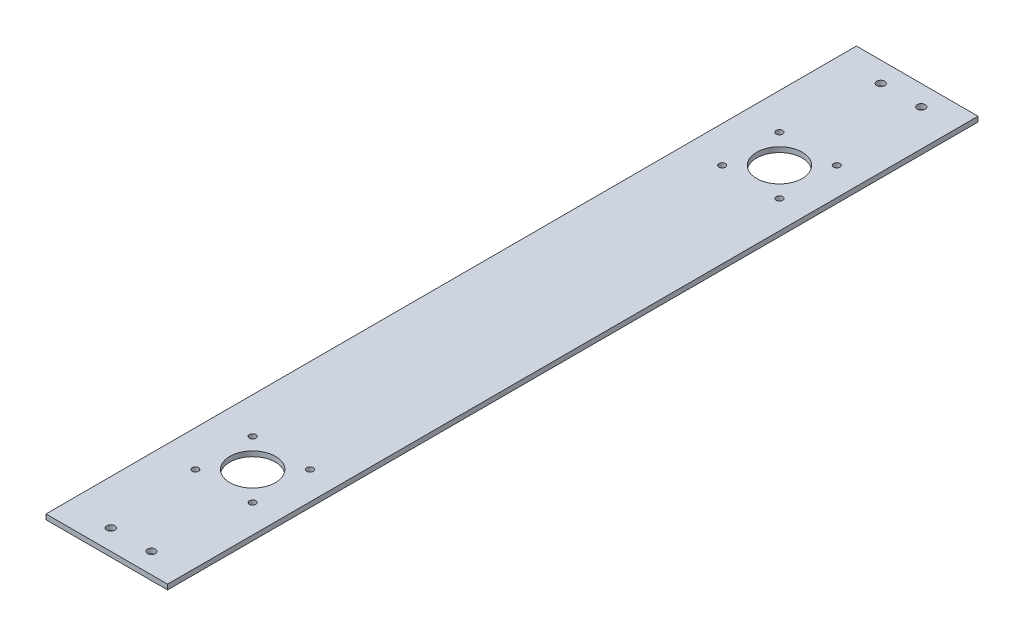
from build123d import *

# Parameters (mm, degrees)
SKETCH1_W               = 406.4
SKETCH1_H               = 508
BOSS_EXTRUDE1_DEPTH     = 3.175
SKETCH2_R               = 14.2875
CUT_EXTRUDE1_DEPTH      = 3.175
SKETCH3_R               = 2.4892
CUT_EXTRUDE2_DEPTH      = 1
CUT_EXTRUDE2_DEPTH_BACK = 4.175
SKETCH4_R               = 2.0193
CUT_EXTRUDE3_DEPTH      = 1
CUT_EXTRUDE3_DEPTH_BACK = 4.175
CUT_EXTRUDE4_REACH      = 5.175
SKETCH5_W               = 124.46
SKETCH5_H               = 508
SKETCH5_W_2             = 205.74


with BuildPart() as part:
    # Sketch1 → Boss-Extrude1 (new body)
    with BuildSketch(Plane(origin=(0, 0, 0), x_dir=(1, 0, 0), z_dir=(0, 1, 0))):
        with Locations((203.2, 254)):
            Rectangle(SKETCH1_W, SKETCH1_H)
    extrude(amount=BOSS_EXTRUDE1_DEPTH)

    # Sketch2 → Cut-Extrude1 (cut)
    with BuildSketch(Plane(origin=(0, 3.175, 0), x_dir=(1, 0, 0), z_dir=(0, 1, 0))):
        with Locations((50.8, 419.1)):
            Circle(SKETCH2_R)
        with Locations((165.1, 419.1)):
            Circle(SKETCH2_R)
        with Locations((50.8, 88.9)):
            Circle(SKETCH2_R)
        with Locations((165.1, 88.9)):
            Circle(SKETCH2_R)
    extrude(amount=-CUT_EXTRUDE1_DEPTH, mode=Mode.SUBTRACT)

    # Sketch3 → Cut-Extrude2 (cut, two sides)
    with BuildSketch(Plane(origin=(0, 3.175, 0), x_dir=(1, 0, 0), z_dir=(0, 1, 0))) as cut_extrude2_sk:
        with Locations((38.1, 12.7)):
            Circle(SKETCH3_R)
        with Locations((63.5, 12.7)):
            Circle(SKETCH3_R)
        with Locations((152.4, 12.7)):
            Circle(SKETCH3_R)
        with Locations((177.8, 12.7)):
            Circle(SKETCH3_R)
        with Locations((203.2, 12.7)):
            Circle(SKETCH3_R)
        with Locations((228.6, 12.7)):
            Circle(SKETCH3_R)
        with Locations((254, 12.7)):
            Circle(SKETCH3_R)
        with Locations((279.4, 12.7)):
            Circle(SKETCH3_R)
        with Locations((304.8, 12.7)):
            Circle(SKETCH3_R)
        with Locations((330.2, 12.7)):
            Circle(SKETCH3_R)
        with Locations((355.6, 12.7)):
            Circle(SKETCH3_R)
        with Locations((381, 12.7)):
            Circle(SKETCH3_R)
        with Locations((381, 495.3)):
            Circle(SKETCH3_R)
        with Locations((355.6, 495.3)):
            Circle(SKETCH3_R)
        with Locations((330.2, 495.3)):
            Circle(SKETCH3_R)
        with Locations((304.8, 495.3)):
            Circle(SKETCH3_R)
        with Locations((279.4, 495.3)):
            Circle(SKETCH3_R)
        with Locations((254, 495.3)):
            Circle(SKETCH3_R)
        with Locations((228.6, 495.3)):
            Circle(SKETCH3_R)
        with Locations((203.2, 495.3)):
            Circle(SKETCH3_R)
        with Locations((177.8, 495.3)):
            Circle(SKETCH3_R)
        with Locations((152.4, 495.3)):
            Circle(SKETCH3_R)
        with Locations((63.5, 495.3)):
            Circle(SKETCH3_R)
        with Locations((38.1, 495.3)):
            Circle(SKETCH3_R)
        with Locations((101.6, 12.7)):
            Circle(SKETCH3_R)
    extrude(amount=CUT_EXTRUDE2_DEPTH, mode=Mode.SUBTRACT)
    extrude(cut_extrude2_sk.sketch, amount=-CUT_EXTRUDE2_DEPTH_BACK, mode=Mode.SUBTRACT)

    # Sketch4 → Cut-Extrude3 (cut, two sides)
    with BuildSketch(Plane(origin=(0, 3.175, 0), x_dir=(1, 0, 0), z_dir=(0, 1, 0))) as cut_extrude3_sk:
        with Locations((76.2, 419.1)):
            Circle(SKETCH4_R)
        with Locations((25.4, 419.1)):
            Circle(SKETCH4_R)
        with Locations((38.1, 441.097045256)):
            Circle(SKETCH4_R)
        with Locations((63.5, 441.097045256)):
            Circle(SKETCH4_R)
        with Locations((63.5, 397.102954744)):
            Circle(SKETCH4_R)
        with Locations((38.1, 397.102954744)):
            Circle(SKETCH4_R)
        with Locations((147.139487788, 437.060512212)):
            Circle(SKETCH4_R)
        with Locations((183.060512212, 437.060512212)):
            Circle(SKETCH4_R)
        with Locations((183.060512212, 401.139487788)):
            Circle(SKETCH4_R)
        with Locations((147.139487788, 401.139487788)):
            Circle(SKETCH4_R)
        with Locations((147.139487788, 106.860512212)):
            Circle(SKETCH4_R)
        with Locations((183.060512212, 106.860512212)):
            Circle(SKETCH4_R)
        with Locations((183.060512212, 70.939487788)):
            Circle(SKETCH4_R)
        with Locations((147.139487788, 70.939487788)):
            Circle(SKETCH4_R)
        with Locations((38.1, 110.897045256)):
            Circle(SKETCH4_R)
        with Locations((63.5, 110.897045256)):
            Circle(SKETCH4_R)
        with Locations((63.5, 66.902954744)):
            Circle(SKETCH4_R)
        with Locations((38.1, 66.902954744)):
            Circle(SKETCH4_R)
        with Locations((25.4, 88.9)):
            Circle(SKETCH4_R)
        with Locations((76.2, 88.9)):
            Circle(SKETCH4_R)
    extrude(amount=CUT_EXTRUDE3_DEPTH, mode=Mode.SUBTRACT)
    extrude(cut_extrude3_sk.sketch, amount=-CUT_EXTRUDE3_DEPTH_BACK, mode=Mode.SUBTRACT)

    # Sketch5 → Cut-Extrude4 (cut, up to next)
    with BuildSketch(Plane(origin=(0, 3.175, 0), x_dir=(1, 0, 0), z_dir=(0, 1, 0)), mode=Mode.PRIVATE) as cut_extrude4_sk1:
        with Locations((62.23, 254)):
            Rectangle(SKETCH5_W, SKETCH5_H)
    cut_extrude4_tool1 = extrude(cut_extrude4_sk1.sketch, amount=-CUT_EXTRUDE4_REACH, mode=Mode.PRIVATE) & part.part
    add(cut_extrude4_tool1.solids().sort_by_distance((62.23, 3.175, -254))[0], mode=Mode.SUBTRACT)
    # Sketch5 → Cut-Extrude4 (cut, up to next)
    with BuildSketch(Plane(origin=(0, 3.175, 0), x_dir=(1, 0, 0), z_dir=(0, 1, 0)), mode=Mode.PRIVATE) as cut_extrude4_sk2:
        with Locations((303.53, 254)):
            Rectangle(SKETCH5_W_2, SKETCH5_H)
    cut_extrude4_tool2 = extrude(cut_extrude4_sk2.sketch, amount=-CUT_EXTRUDE4_REACH, mode=Mode.PRIVATE) & part.part
    add(cut_extrude4_tool2.solids().sort_by_distance((303.53, 3.175, -254))[0], mode=Mode.SUBTRACT)


solid = part.part
